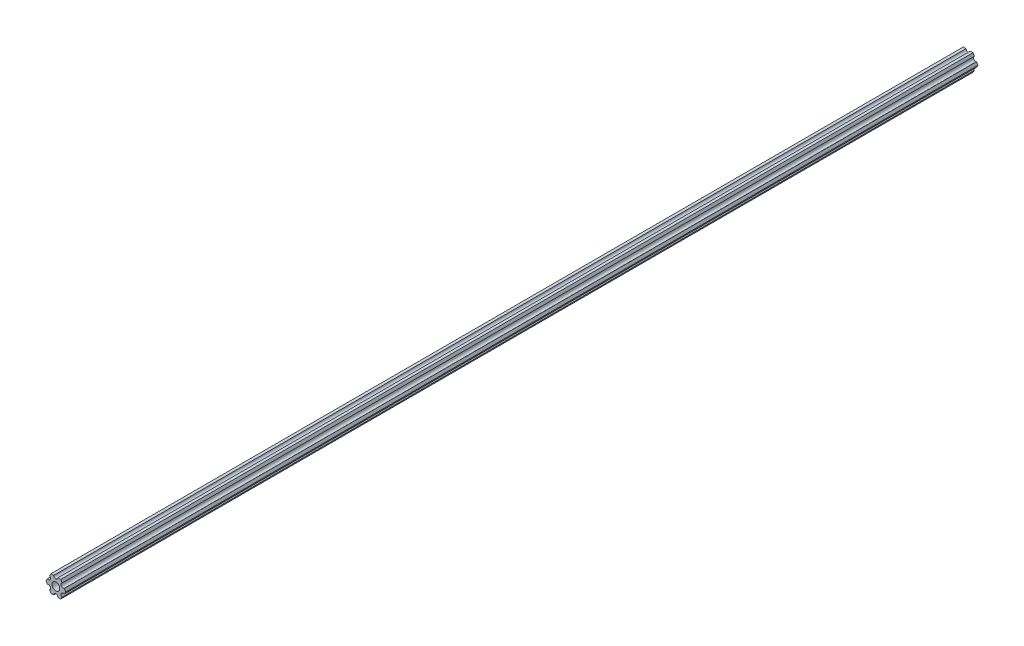
from build123d import *

# Parameters (mm, degrees)
SKETCH1_R           = 2.9337
BOSS_EXTRUDE1_DEPTH = 681.0248


with BuildPart() as part:
    # Sketch1 → Boss-Extrude1 (new body)
    with BuildSketch(Plane.XY):
        with BuildLine():
            Line((-4.70551159, -4.549815043), (-3.666174521, -6.349999904))
            Line((-3.666174521, -6.349999904), (-1.587501154, -6.349999904))
            ThreePointArc((-1.587501154, -6.349999904), (-3.85e-07, -4.762499134), (1.587501154, -6.349999904))
            Line((1.587501154, -6.349999904), (3.666173825, -6.349999904))
            Line((3.666173825, -6.349999904), (4.705510929, -4.549815232))
            ThreePointArc((4.705510929, -4.549815232), (4.124445601, -2.381249904), (6.293010929, -1.800184575))
            Line((6.293010929, -1.800184575), (7.332348034, 9.6e-08))
            Line((7.332348034, 9.6e-08), (6.293011178, 1.800184715))
            ThreePointArc((6.293011178, 1.800184715), (4.124445902, 2.381250241), (4.705511428, 4.549815516))
            Line((4.705511428, 4.549815516), (3.666174521, 6.350000222))
            Line((3.666174521, 6.350000222), (1.587498846, 6.350000222))
            ThreePointArc((1.587498846, 6.350000222), (3.85e-07, 4.762501761), (-1.587498846, 6.350000222))
            Line((-1.587498846, 6.350000222), (-3.666173825, 6.350000222))
            Line((-3.666173825, 6.350000222), (-4.705511038, 4.549815614))
            ThreePointArc((-4.705511038, 4.549815614), (-4.124445841, 2.38125025), (-6.293011205, 1.800185053))
            Line((-6.293011205, 1.800185053), (-7.332348419, 4.44e-07))
            Line((-7.332348419, 4.44e-07), (-6.293011423, -1.80018429))
            ThreePointArc((-6.293011423, -1.80018429), (-4.12444613, -2.38124975), (-4.70551159, -4.549815043))
        make_face()
        Circle(SKETCH1_R, mode=Mode.SUBTRACT)
    extrude(amount=-BOSS_EXTRUDE1_DEPTH)


solid = part.part
